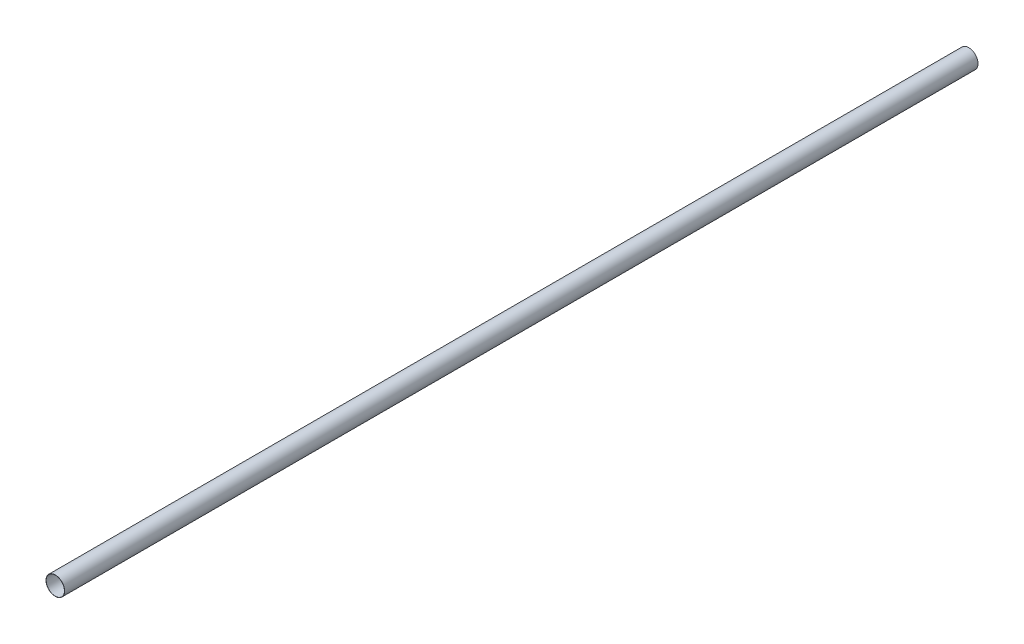
from build123d import *

# Parameters (mm, degrees)
SKETCH1_R           = 51
SKETCH1_R_2         = 50
BOSS_EXTRUDE1_DEPTH = 5000


with BuildPart() as part:
    # Sketch1 → Boss-Extrude1 (new body)
    with BuildSketch(Plane.XY):
        Circle(SKETCH1_R)
        Circle(SKETCH1_R_2, mode=Mode.SUBTRACT)
    extrude(amount=BOSS_EXTRUDE1_DEPTH)


solid = part.part
